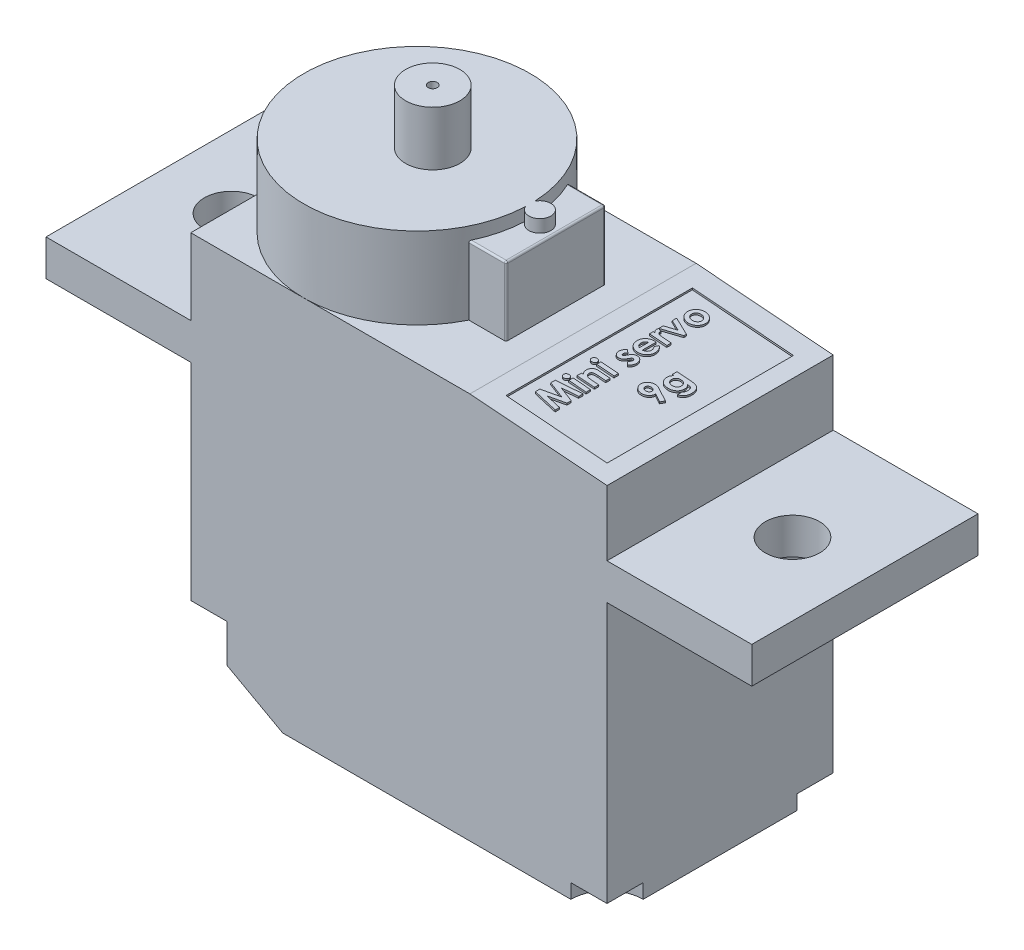
from build123d import *

# Parameters (mm, degrees)
SKETCH1_W                = 23
SKETCH1_H                = 12.5
BOSS_EXTRUDE1_DEPTH      = 15.2
SKETCH2_W                = 39
SKETCH2_H                = 12.5
BOSS_EXTRUDE2_DEPTH      = 2
SKETCH3_W                = 23
SKETCH3_H                = 12.5
BOSS_EXTRUDE3_DEPTH      = 4.2
CUT_EXTRUDE1_DEPTH       = 13.5
SKETCH5_R                = 6.250000507
BOSS_EXTRUDE4_DEPTH      = 4.5
SKETCH6_W                = 4.84744246
SKETCH6_H                = 5.5
BOSS_EXTRUDE5_DEPTH      = 3.8
SKETCH7_R                = 0.605889216
BOSS_EXTRUDE7_DEPTH      = 0.7
SKETCH8_R                = 1.5
BOSS_EXTRUDE8_DEPTH      = 3
CUT_EXTRUDE2_DEPTH       = 13.500001013
SKETCH13_R               = 0.25
CUT_EXTRUDE3_DEPTH       = 7.5
CUT_EXTRUDE12_DEPTH      = 0.8
CUT_EXTRUDE13_DEPTH      = 3.8
SKETCH17_W               = 5.6
SKETCH17_H               = 10.3
CUT_EXTRUDE14_DEPTH      = 0.1
SKETCH19_W               = 0.966746795
SKETCH19_H               = 0.237446581
BOSS_EXTRUDE9_DEPTH      = 0.1
FILLET3_R                = 0.1
F_3_0_3_DIAMETER_HOLE1_D = 3


with BuildPart() as part:
    # Sketch1 → Boss-Extrude1 (new body)
    with BuildSketch(Plane(origin=(0, 0, 0), x_dir=(1, 0, 0), z_dir=(0, 1, 0))):
        Rectangle(SKETCH1_W, SKETCH1_H)
    extrude(amount=BOSS_EXTRUDE1_DEPTH)

    # Sketch2 → Boss-Extrude2 (add)
    with BuildSketch(Plane(origin=(0, 15.2, 0), x_dir=(1, 0, 0), z_dir=(0, 1, 0))):
        Rectangle(SKETCH2_W, SKETCH2_H)
    extrude(amount=BOSS_EXTRUDE2_DEPTH)

    # Sketch3 → Boss-Extrude3 (add)
    with BuildSketch(Plane(origin=(0, 17.2, 0), x_dir=(1, 0, 0), z_dir=(0, 1, 0))):
        Rectangle(SKETCH3_W, SKETCH3_H)
    extrude(amount=BOSS_EXTRUDE3_DEPTH)

    # Sketch4 → Cut-Extrude1 (cut, through all)
    with BuildSketch(Plane.XY.offset(6.25)):
        Polygon((11.5, 20.8), (3.92372123, 21.4), (11.5, 21.4), align=None)
    extrude(amount=-CUT_EXTRUDE1_DEPTH, mode=Mode.SUBTRACT)

    # Sketch5 → Boss-Extrude4 (add)
    with BuildSketch(Plane(origin=(0, 21.4, 0), x_dir=(1, 0, 0), z_dir=(0, 1, 0))):
        with Locations((-5.249999493, 5.07e-07)):
            Circle(SKETCH5_R)
    extrude(amount=BOSS_EXTRUDE4_DEPTH)

    # Sketch6 → Boss-Extrude5 (add)
    with BuildSketch(Plane(origin=(0, 21.4, 0), x_dir=(1, 0, 0), z_dir=(0, 1, 0))):
        Rectangle(SKETCH6_W, SKETCH6_H)
    extrude(amount=BOSS_EXTRUDE5_DEPTH)

    # Sketch7 → Boss-Extrude7 (add)
    with BuildSketch(Plane(origin=(0, 25.2, 0), x_dir=(1, 0, 0), z_dir=(0, 1, 0))):
        with Locations((1.542332806, 0)):
            Circle(SKETCH7_R)
    extrude(amount=BOSS_EXTRUDE7_DEPTH)

    # Sketch8 → Boss-Extrude8 (add)
    with BuildSketch(Plane(origin=(0, 25.9, 0), x_dir=(1, 0, 0), z_dir=(0, 1, 0))):
        with Locations((-4.378885872, 0)):
            Circle(SKETCH8_R)
    extrude(amount=BOSS_EXTRUDE8_DEPTH)

    # Sketch9 → Cut-Extrude2 (cut, through all)
    with BuildSketch(Plane.XY.offset(6.25)):
        Polygon((-11.5, 0), (-6.42062996, 0), (-11.5, 2.8), align=None)
    extrude(amount=-CUT_EXTRUDE2_DEPTH, mode=Mode.SUBTRACT)

    # Sketch13 → Cut-Extrude3 (cut)
    with BuildSketch(Plane(origin=(0, 28.9, 0), x_dir=(1, 0, 0), z_dir=(0, 1, 0))):
        with Locations((-4.378885872, 0)):
            Circle(SKETCH13_R)
    extrude(amount=-CUT_EXTRUDE3_DEPTH, mode=Mode.SUBTRACT)

    # Sketch15 → Cut-Extrude12 (cut)
    with BuildSketch(Plane.XZ):
        with BuildLine():
            Line((9.5, 6.25), (11.5, 6.25))
            Line((11.5, 6.25), (11.5, 4.25))
            ThreePointArc((11.5, 4.25), (10.085786438, 4.835786438), (9.5, 6.25))
        make_face()
        with BuildLine():
            Line((11.5, -6.25), (11.5, -4.25))
            ThreePointArc((11.5, -4.25), (10.085786438, -4.835786438), (9.5, -6.25))
            Line((9.5, -6.25), (11.5, -6.25))
        make_face()
    extrude(amount=-CUT_EXTRUDE12_DEPTH, mode=Mode.SUBTRACT)

    # Sketch16 → Cut-Extrude13 (cut)
    with BuildSketch(Plane.XZ):
        with BuildLine():
            Line((-11.5, 4.25), (-11.5, 6.25))
            Line((-11.5, 6.25), (-9.5, 6.25))
            ThreePointArc((-9.5, 6.25), (-10.085786438, 4.835786438), (-11.5, 4.25))
        make_face()
        with BuildLine():
            Line((-11.5, -6.25), (-9.5, -6.25))
            ThreePointArc((-9.5, -6.25), (-10.085786438, -4.835786438), (-11.5, -4.25))
            Line((-11.5, -4.25), (-11.5, -6.25))
        make_face()
    extrude(amount=-CUT_EXTRUDE13_DEPTH, mode=Mode.SUBTRACT)

    # Sketch17 → Cut-Extrude14 (cut)
    with BuildSketch(Plane(origin=(1.708655801, 21.575421113, 0), x_dir=(0.996878786, -0.078947368, 0), z_dir=(0.078947368, 0.996878786, 0))):
        with Locations((6.02200077, -0.1)):
            Rectangle(SKETCH17_W, SKETCH17_H)
    extrude(amount=-CUT_EXTRUDE14_DEPTH, mode=Mode.SUBTRACT)

    # Sketch19 → Boss-Extrude9 (add)
    with BuildSketch(Plane(origin=(1.700761064, 21.475733235, 0), x_dir=(0.996878786, -0.078947368, 0), z_dir=(0.078947368, 0.996878786, 0))):
        Polygon((3.804977761, -4.209998915), (3.804977761, -3.963542084), (4.727733337, -3.661698718), (3.804977761, -3.357735293), (3.804977761, -3.113663528), (5.127894428, -2.889997329), (5.127894428, -3.130358991), (4.292326269, -3.271607906), (5.127894428, -3.54668553), (5.127894428, -3.77830195), (4.292326269, -4.05178953), (5.127894428, -4.192773437), (5.127894428, -4.433400107), align=None)
        with BuildLine():
            add(Edge.make_bspline(
                [(3.754096351, -2.602199352), (3.75459237, -2.591961906), (3.755566352, -2.571859693), (3.765250821, -2.543162418), (3.779962144, -2.516577279), (3.800736934, -2.493321996), (3.825461159, -2.473783527), (3.853306295, -2.459094906), (3.884008461, -2.450748481), (3.905189995, -2.449608003), (3.916015839, -2.449025107)],
                knots=[0, 0, 0, 0, 3.0615e-05, 6.0115e-05, 8.9897e-05, 0.000121258, 0.000152962, 0.000184016, 0.000215069, 0.000247531, 0.000247531, 0.000247531, 0.000247531], degree=3))
            add(Edge.make_bspline(
                [(3.916015839, -2.449025107), (3.926755073, -2.449605165), (3.947766142, -2.450740036), (3.978075272, -2.459095732), (4.005632722, -2.473557801), (4.02994352, -2.493040352), (4.050299111, -2.516159468), (4.065658572, -2.542001345), (4.074734342, -2.570515674), (4.075802775, -2.590299071), (4.076345283, -2.600344301)],
                knots=[0, 0, 0, 0, 3.2198e-05, 6.2995e-05, 9.3457e-05, 0.000124953, 0.00015594, 0.000185393, 0.000214561, 0.000244648, 0.000244648, 0.000244648, 0.000244648], degree=3))
            add(Edge.make_bspline(
                [(4.076345283, -2.600344301), (4.075838926, -2.610664087), (4.074844674, -2.630927394), (4.065284296, -2.66004514), (4.049948219, -2.686657776), (4.028907377, -2.710017641), (4.004029509, -2.729557175), (3.975889403, -2.743906483), (3.945069935, -2.752707621), (3.923583116, -2.753769392), (3.912570743, -2.754313568)],
                knots=[0, 0, 0, 0, 3.0879e-05, 6.0632e-05, 9.0905e-05, 0.000122442, 0.000154354, 0.000185288, 0.000216666, 0.000249656, 0.000249656, 0.000249656, 0.000249656], degree=3))
            add(Edge.make_bspline(
                [(3.912570743, -2.754313568), (3.902009274, -2.753725713), (3.881262794, -2.752570957), (3.851287745, -2.744252881), (3.824083661, -2.729750005), (3.799821827, -2.710462573), (3.779512344, -2.687309295), (3.764886508, -2.660902407), (3.755672611, -2.632306853), (3.754627196, -2.61233881), (3.754096351, -2.602199352)],
                knots=[0, 0, 0, 0, 3.167e-05, 6.2212e-05, 9.2439e-05, 0.000123562, 0.00015475, 0.000184171, 0.000213591, 0.000243942, 0.000243942, 0.000243942, 0.000243942], degree=3))
        make_face()
        with Locations((4.64452103, -2.601669338)):
            Rectangle(SKETCH19_W, SKETCH19_H)
        with BuildLine():
            Line((4.161147633, -2.262459936), (4.161147633, -2.025013355))
            Line((4.161147633, -2.025013355), (4.263440468, -2.025013355))
            add(Edge.make_bspline(
                [(4.263440468, -2.025013355), (4.252895408, -2.011471852), (4.232741746, -1.985591407), (4.207153626, -1.946137744), (4.185757128, -1.909151347), (4.169870375, -1.873291895), (4.158236054, -1.838291066), (4.150419303, -1.80328736), (4.145017255, -1.768035338), (4.144463712, -1.744302244), (4.144187163, -1.732445246)],
                knots=[0, 0, 0, 0, 5.1465e-05, 9.8359e-05, 0.000140959, 0.000179518, 0.000215804, 0.000251419, 0.000287023, 0.000322569, 0.000322569, 0.000322569, 0.000322569], degree=3))
            add(Edge.make_bspline(
                [(4.144187163, -1.732445246), (4.144472419, -1.720413512), (4.145032681, -1.696782417), (4.15005373, -1.662119501), (4.157614767, -1.628794919), (4.16856507, -1.59683021), (4.182668476, -1.566184116), (4.199989685, -1.537046684), (4.220179715, -1.50914136), (4.235873487, -1.492194884), (4.243829925, -1.483603349)],
                knots=[0, 0, 0, 0, 3.6076e-05, 7.0856e-05, 0.000104861, 0.000138467, 0.000172024, 0.000205884, 0.000240019, 0.000275121, 0.000275121, 0.000275121, 0.000275121], degree=3))
            add(Edge.make_bspline(
                [(4.243829925, -1.483603349), (4.251177599, -1.476696585), (4.265926724, -1.46283251), (4.291171464, -1.445399264), (4.318743463, -1.430347031), (4.348923799, -1.41826973), (4.381735287, -1.409035118), (4.416900166, -1.402131615), (4.454686424, -1.39820407), (4.480649169, -1.397723188), (4.493996859, -1.397475962)],
                knots=[0, 0, 0, 0, 3.0217e-05, 6.0654e-05, 9.1724e-05, 0.000124301, 0.000157936, 0.000193849, 0.00023169, 0.000271728, 0.000271728, 0.000271728, 0.000271728], degree=3))
            Line((4.493996859, -1.397475962), (5.127894428, -1.397475962))
            Line((5.127894428, -1.397475962), (5.127894428, -1.634922543))
            Line((5.127894428, -1.634922543), (4.708122793, -1.634922543))
            add(Edge.make_bspline(
                [(4.708122793, -1.634922543), (4.694430569, -1.634972733), (4.668191963, -1.635068913), (4.630640648, -1.635808044), (4.596726682, -1.637249596), (4.566389395, -1.638567758), (4.53973313, -1.64113921), (4.516512884, -1.64350685), (4.496996733, -1.64701419), (4.476038704, -1.651710565), (4.453705894, -1.659720001), (4.43031827, -1.672584349), (4.410099694, -1.688292983), (4.393521681, -1.707140929), (4.380279706, -1.728484577), (4.371449805, -1.75249671), (4.365584458, -1.778628512), (4.36498473, -1.796895655), (4.364673274, -1.806382295)],
                knots=[0, 0, 0, 0, 4.1077e-05, 7.8716e-05, 0.000112663, 0.000142916, 0.000169788, 0.000192995, 0.000212906, 0.000229234, 0.000257399, 0.000283731, 0.00030902, 0.0003338, 0.000358662, 0.00038391, 0.000410211, 0.000438627, 0.000438627, 0.000438627, 0.000438627], degree=3))
            add(Edge.make_bspline(
                [(4.364673274, -1.806382295), (4.365300058, -1.818714845), (4.366526168, -1.84283971), (4.375733221, -1.877747918), (4.391472627, -1.909699074), (4.412865203, -1.938806589), (4.439740262, -1.964369847), (4.471892035, -1.985267733), (4.508285748, -2.002626573), (4.534841665, -2.010043608), (4.548588372, -2.013883046)],
                knots=[0, 0, 0, 0, 3.6973e-05, 7.2326e-05, 0.000107409, 0.00014324, 0.000180167, 0.000218019, 0.000257852, 0.000300599, 0.000300599, 0.000300599, 0.000300599], degree=3))
            add(Edge.make_bspline(
                [(4.548588372, -2.013883046), (4.552904782, -2.014838435), (4.562531244, -2.016969143), (4.578794152, -2.018720308), (4.598175752, -2.021173637), (4.620852782, -2.02205164), (4.646799373, -2.02367027), (4.675967638, -2.024244313), (4.708473615, -2.024836211), (4.731177961, -2.024952351), (4.743103763, -2.025013355)],
                knots=[0, 0, 0, 0, 1.3253e-05, 2.9557e-05, 4.9018e-05, 7.1847e-05, 9.7587e-05, 0.000127014, 0.000159349, 0.000195126, 0.000195126, 0.000195126, 0.000195126], degree=3))
            Line((4.743103763, -2.025013355), (5.127894428, -2.025013355))
            Line((5.127894428, -2.025013355), (5.127894428, -2.262459936))
            Line((5.127894428, -2.262459936), (4.161147633, -2.262459936))
        make_face()
        with BuildLine():
            add(Edge.make_bspline(
                [(3.754096351, -1.058796575), (3.75459237, -1.048559128), (3.755566352, -1.028456916), (3.765250821, -0.99975964), (3.779962144, -0.973174502), (3.800736934, -0.949919219), (3.825461159, -0.930380749), (3.853306295, -0.915692128), (3.884008461, -0.907345704), (3.905189995, -0.906205225), (3.916015839, -0.905622329)],
                knots=[0, 0, 0, 0, 3.0615e-05, 6.0115e-05, 8.9897e-05, 0.000121258, 0.000152962, 0.000184016, 0.000215069, 0.000247531, 0.000247531, 0.000247531, 0.000247531], degree=3))
            add(Edge.make_bspline(
                [(3.916015839, -0.905622329), (3.926755073, -0.906202387), (3.947766142, -0.907337258), (3.978075272, -0.915692954), (4.005632722, -0.930155023), (4.02994352, -0.949637574), (4.050299111, -0.97275669), (4.065658572, -0.998598568), (4.074734342, -1.027112897), (4.075802775, -1.046896293), (4.076345283, -1.056941523)],
                knots=[0, 0, 0, 0, 3.2198e-05, 6.2995e-05, 9.3457e-05, 0.000124953, 0.00015594, 0.000185393, 0.000214561, 0.000244648, 0.000244648, 0.000244648, 0.000244648], degree=3))
            add(Edge.make_bspline(
                [(4.076345283, -1.056941523), (4.075838926, -1.067261309), (4.074844674, -1.087524616), (4.065284296, -1.116642362), (4.049948219, -1.143254998), (4.028907377, -1.166614864), (4.004029509, -1.186154397), (3.975889403, -1.200503706), (3.945069935, -1.209304843), (3.923583116, -1.210366614), (3.912570743, -1.210910791)],
                knots=[0, 0, 0, 0, 3.0879e-05, 6.0632e-05, 9.0905e-05, 0.000122442, 0.000154354, 0.000185288, 0.000216666, 0.000249656, 0.000249656, 0.000249656, 0.000249656], degree=3))
            add(Edge.make_bspline(
                [(3.912570743, -1.210910791), (3.902009274, -1.210322936), (3.881262794, -1.209168179), (3.851287745, -1.200850104), (3.824083661, -1.186347227), (3.799821827, -1.167059795), (3.779512344, -1.143906517), (3.764886508, -1.117499629), (3.755672611, -1.088904075), (3.754627196, -1.068936033), (3.754096351, -1.058796575)],
                knots=[0, 0, 0, 0, 3.167e-05, 6.2212e-05, 9.2439e-05, 0.000123562, 0.00015475, 0.000184171, 0.000213591, 0.000243942, 0.000243942, 0.000243942, 0.000243942], degree=3))
        make_face()
        with Locations((4.64452103, -1.05826656)):
            Rectangle(SKETCH19_W, SKETCH19_H)
        with BuildLine():
            Line((4.310346768, 0.383373397), (4.466436095, 0.238149372))
            add(Edge.make_bspline(
                [(4.466436095, 0.238149372), (4.458411661, 0.230897641), (4.443063959, 0.217027826), (4.42214161, 0.19579448), (4.404719475, 0.17487734), (4.390084155, 0.154666195), (4.378860614, 0.134748261), (4.370785527, 0.115289102), (4.365659342, 0.09627938), (4.364995777, 0.083678933), (4.364673274, 0.077554921)],
                knots=[0, 0, 0, 0, 3.2445e-05, 6.2054e-05, 8.9335e-05, 0.000114042, 0.000136822, 0.000157737, 0.000177148, 0.000195502, 0.000195502, 0.000195502, 0.000195502], degree=3))
            add(Edge.make_bspline(
                [(4.364673274, 0.077554921), (4.364862134, 0.071358036), (4.365223742, 0.05949293), (4.36832543, 0.042748605), (4.373695023, 0.028037596), (4.38101428, 0.015589477), (4.390030852, 0.005588438), (4.400345598, -0.001413756), (4.411637705, -0.006115794), (4.419658925, -0.006513556), (4.423769912, -0.006717415)],
                knots=[0, 0, 0, 0, 1.8581e-05, 3.5576e-05, 5.0837e-05, 6.5335e-05, 7.8651e-05, 9.0853e-05, 0.000102517, 0.000114779, 0.000114779, 0.000114779, 0.000114779], degree=3))
            add(Edge.make_bspline(
                [(4.423769912, -0.006717415), (4.429999834, -0.006026723), (4.442926199, -0.004593619), (4.457918854, 0.005249822), (4.468978629, 0.018273405), (4.479270384, 0.033285831), (4.490777669, 0.053616541), (4.498657043, 0.069039934), (4.503007108, 0.077554921)],
                knots=[0, 0, 0, 0, 1.8607e-05, 3.8608e-05, 5.1746e-05, 6.9831e-05, 9.3104e-05, 0.000121788, 0.000121788, 0.000121788, 0.000121788], degree=3))
            Line((4.503007108, 0.077554921), (4.546468313, 0.163417301))
            add(Edge.make_bspline(
                [(4.546468313, 0.163417301), (4.552012371, 0.174342414), (4.562768887, 0.195539185), (4.580166995, 0.22531091), (4.596910375, 0.2529569), (4.614548494, 0.277363506), (4.6315577, 0.299650815), (4.649266113, 0.318725676), (4.66663527, 0.335555581), (4.689956301, 0.354300833), (4.721007202, 0.37305852), (4.761391978, 0.388694119), (4.804634, 0.398665374), (4.834563654, 0.399768531), (4.849901723, 0.400333868)],
                knots=[0, 0, 0, 0, 3.6744e-05, 7.1291e-05, 0.000103427, 0.000133648, 0.000161586, 0.00018747, 0.00021165, 0.000234082, 0.000277122, 0.000319837, 0.000363557, 0.000409513, 0.000409513, 0.000409513, 0.000409513], degree=3))
            add(Edge.make_bspline(
                [(4.849901723, 0.400333868), (4.860249279, 0.399992958), (4.880502193, 0.399325709), (4.910315033, 0.395114986), (4.938653049, 0.387529508), (4.96592948, 0.377647433), (4.991566802, 0.364076491), (5.015941096, 0.347877032), (5.039267105, 0.32895112), (5.060771519, 0.306951087), (5.08069072, 0.282714428), (5.097975095, 0.256157985), (5.112234484, 0.227511698), (5.124309895, 0.197156425), (5.133541298, 0.164651356), (5.140075024, 0.130151664), (5.144149087, 0.093641178), (5.144615633, 0.068643987), (5.144854898, 0.055824319)],
                knots=[0, 0, 0, 0, 3.1047e-05, 6.0766e-05, 9.0077e-05, 0.000118923, 0.000147607, 0.00017686, 0.000206619, 0.000237539, 0.000268994, 0.000300601, 0.000332364, 0.000364843, 0.000398478, 0.00043356, 0.000470083, 0.000508532, 0.000508532, 0.000508532, 0.000508532], degree=3))
            add(Edge.make_bspline(
                [(5.144854898, 0.055824319), (5.144314006, 0.038838887), (5.143252284, 0.005497979), (5.135856475, -0.043194003), (5.123054206, -0.08917216), (5.105119865, -0.132474321), (5.082266598, -0.173365705), (5.053910696, -0.211262336), (5.02079095, -0.246821188), (4.995389648, -0.267509698), (4.982405396, -0.278084936)],
                knots=[0, 0, 0, 0, 5.095e-05, 0.000100011, 0.000147334, 0.000193792, 0.000240304, 0.000287476, 0.000335471, 0.000385659, 0.000385659, 0.000385659, 0.000385659], degree=3))
            Line((4.982405396, -0.278084936), (4.822605966, -0.134185948))
            add(Edge.make_bspline(
                [(4.822605966, -0.134185948), (4.829976995, -0.127155304), (4.844652167, -0.113157812), (4.864364835, -0.089970439), (4.881622161, -0.064861726), (4.896561886, -0.038529818), (4.908343449, -0.011961111), (4.917871849, 0.013266089), (4.922989826, 0.037245738), (4.923924579, 0.052713802), (4.924368787, 0.060064436)],
                knots=[0, 0, 0, 0, 3.0545e-05, 6.0813e-05, 9.1099e-05, 0.000121833, 0.000151485, 0.000178225, 0.000202601, 0.000224675, 0.000224675, 0.000224675, 0.000224675], degree=3))
            add(Edge.make_bspline(
                [(4.924368787, 0.060064436), (4.924155729, 0.067418104), (4.923746173, 0.081553884), (4.919488871, 0.101646665), (4.912325846, 0.11944803), (4.902413191, 0.134570882), (4.891022432, 0.147005385), (4.878231414, 0.156115914), (4.86438933, 0.161763388), (4.854721202, 0.162513408), (4.849901723, 0.162887286)],
                knots=[0, 0, 0, 0, 2.2035e-05, 4.2358e-05, 6.1256e-05, 7.9265e-05, 9.6326e-05, 0.000111545, 0.000126063, 0.000140493, 0.000140493, 0.000140493, 0.000140493], degree=3))
            add(Edge.make_bspline(
                [(4.849901723, 0.162887286), (4.845356364, 0.162568182), (4.836023866, 0.161913), (4.822248431, 0.1567259), (4.80860854, 0.148582051), (4.795065737, 0.137286977), (4.781729904, 0.122690382), (4.768707857, 0.104844504), (4.755304854, 0.084161048), (4.747305057, 0.068883071), (4.743103763, 0.060859458)],
                knots=[0, 0, 0, 0, 1.3609e-05, 2.7941e-05, 4.3621e-05, 6.113e-05, 8.0633e-05, 0.000102787, 0.00012734, 0.000154497, 0.000154497, 0.000154497, 0.000154497], degree=3))
            Line((4.743103763, 0.060859458), (4.703352661, -0.017847723))
            add(Edge.make_bspline(
                [(4.703352661, -0.017847723), (4.693778669, -0.035701654), (4.675400194, -0.069974507), (4.643885016, -0.116298592), (4.610336481, -0.155505243), (4.574934824, -0.187626409), (4.537779391, -0.213220617), (4.498397119, -0.231074295), (4.457161363, -0.242305889), (4.428963906, -0.243541544), (4.414759662, -0.244163996)],
                knots=[0, 0, 0, 0, 6.0746e-05, 0.00011661, 0.000167717, 0.000215189, 0.000259657, 0.000302469, 0.000344378, 0.000386919, 0.000386919, 0.000386919, 0.000386919], degree=3))
            add(Edge.make_bspline(
                [(4.414759662, -0.244163996), (4.4055536, -0.243948499), (4.387480604, -0.243525443), (4.360942704, -0.239008963), (4.335419189, -0.232212753), (4.310862392, -0.222494372), (4.287146379, -0.210434323), (4.264810914, -0.194978347), (4.243198378, -0.177225831), (4.223001804, -0.156666391), (4.204607635, -0.13400435), (4.188229119, -0.109823584), (4.174713643, -0.083892204), (4.163557278, -0.056471932), (4.154767991, -0.027568018), (4.148768284, 0.002889111), (4.144959167, 0.034792376), (4.144448144, 0.056608233), (4.144187163, 0.067749649)],
                knots=[0, 0, 0, 0, 2.7593e-05, 5.4169e-05, 8.0526e-05, 0.000106707, 0.000133257, 0.000160158, 0.000188016, 0.000217061, 0.000246447, 0.00027548, 0.000304522, 0.000334, 0.000364181, 0.000395, 0.000427017, 0.000460434, 0.000460434, 0.000460434, 0.000460434], degree=3))
            add(Edge.make_bspline(
                [(4.144187163, 0.067749649), (4.14465733, 0.08316049), (4.145591007, 0.113763994), (4.154281028, 0.158729483), (4.1674315, 0.202421445), (4.186430722, 0.244247137), (4.210096034, 0.283950892), (4.238892919, 0.320568862), (4.272048301, 0.354367016), (4.297453842, 0.37360859), (4.310346768, 0.383373397)],
                knots=[0, 0, 0, 0, 4.6187e-05, 9.1721e-05, 0.000136904, 0.000182808, 0.000229165, 0.000275233, 0.000322267, 0.000370732, 0.000370732, 0.000370732, 0.000370732], degree=3))
        make_face()
        with BuildLine():
            Line((4.703882676, 1.569811281), (4.703882676, 0.80738515))
            add(Edge.make_bspline(
                [(4.703882676, 0.80738515), (4.712740184, 0.808943586), (4.730145885, 0.812006038), (4.755373315, 0.818563015), (4.779130002, 0.827218054), (4.801611091, 0.837172271), (4.822737029, 0.848820193), (4.84222609, 0.862574105), (4.860479341, 0.877834698), (4.877229835, 0.894891072), (4.892283044, 0.913306255), (4.905369645, 0.933130455), (4.916540495, 0.954040769), (4.925556522, 0.976275954), (4.932788557, 0.999657643), (4.937750559, 1.024340866), (4.940688078, 1.050237284), (4.941112374, 1.067879601), (4.941329257, 1.07689762)],
                knots=[0, 0, 0, 0, 2.6975e-05, 5.3008e-05, 7.8072e-05, 0.000102746, 0.000126709, 0.000150309, 0.000174196, 0.000197995, 0.000221918, 0.000245438, 0.000269148, 0.000292918, 0.000317311, 0.000342466, 0.000368337, 0.000395388, 0.000395388, 0.000395388, 0.000395388], degree=3))
            add(Edge.make_bspline(
                [(4.941329257, 1.07689762), (4.941041875, 1.087782888), (4.940475936, 1.109219187), (4.935456898, 1.140623525), (4.927875861, 1.170996094), (4.916602223, 1.200049463), (4.902568525, 1.22812017), (4.885084264, 1.254746084), (4.864660388, 1.28038808), (4.848917672, 1.296032719), (4.840891473, 1.304008914)],
                knots=[0, 0, 0, 0, 3.2635e-05, 6.4267e-05, 9.5184e-05, 0.000126387, 0.000157557, 0.000189164, 0.000221777, 0.000255699, 0.000255699, 0.000255699, 0.000255699], degree=3))
            Line((4.840891473, 1.304008914), (4.935499095, 1.502764423))
            add(Edge.make_bspline(
                [(4.935499095, 1.502764423), (4.944146395, 1.496506806), (4.961280701, 1.484107568), (4.985391064, 1.463864728), (5.007894909, 1.44274586), (5.028607158, 1.420708481), (5.047570511, 1.397861302), (5.064561851, 1.373878538), (5.079870497, 1.348958325), (5.093835037, 1.323229223), (5.105669271, 1.296186971), (5.116408458, 1.268236713), (5.124990924, 1.238834091), (5.132595099, 1.208391768), (5.137996385, 1.176570222), (5.141989872, 1.143585618), (5.144416043, 1.109353309), (5.144706875, 1.08608846), (5.144854898, 1.074247546)],
                knots=[0, 0, 0, 0, 3.2013e-05, 6.3433e-05, 9.4366e-05, 0.000124551, 0.000154104, 0.000183371, 0.000212642, 0.000241808, 0.00027111, 0.000301135, 0.000331569, 0.000362935, 0.000395219, 0.00042832, 0.000462589, 0.000498109, 0.000498109, 0.000498109, 0.000498109], degree=3))
            add(Edge.make_bspline(
                [(5.144854898, 1.074247546), (5.1444835, 1.056030143), (5.143756138, 1.020352408), (5.137005181, 0.968167271), (5.125811366, 0.918605866), (5.110595094, 0.871528247), (5.090504848, 0.827137916), (5.06593281, 0.785412903), (5.037350076, 0.745936317), (5.004156771, 0.709914387), (4.968027831, 0.677097346), (4.929227817, 0.648272897), (4.888027809, 0.624153009), (4.844700478, 0.604345272), (4.799134923, 0.588950011), (4.75131126, 0.57785092), (4.701252331, 0.571047045), (4.667156612, 0.570312193), (4.649821177, 0.569938568)],
                knots=[0, 0, 0, 0, 5.4633e-05, 0.000106995, 0.000157527, 0.000206888, 0.000255161, 0.000303384, 0.000351937, 0.000401085, 0.000450054, 0.00049818, 0.000545812, 0.00059301, 0.000640862, 0.000689845, 0.000740105, 0.00079209, 0.00079209, 0.00079209, 0.00079209], degree=3))
            add(Edge.make_bspline(
                [(4.649821177, 0.569938568), (4.632045227, 0.57031587), (4.597071844, 0.571058193), (4.545857031, 0.577792339), (4.496991172, 0.588980696), (4.450406974, 0.604420992), (4.405958742, 0.623928243), (4.364035343, 0.648355015), (4.324490825, 0.677083042), (4.28751018, 0.70978186), (4.254131107, 0.74595639), (4.224383683, 0.784395246), (4.199596154, 0.825530327), (4.179567847, 0.868896362), (4.163295352, 0.914215964), (4.152467366, 0.962012964), (4.145197022, 1.011923702), (4.144527468, 1.046041583), (4.144187163, 1.063382245)],
                knots=[0, 0, 0, 0, 5.3309e-05, 0.000104882, 0.00015464, 0.000203497, 0.000251903, 0.000299993, 0.000348761, 0.000398322, 0.000447828, 0.000496221, 0.000543896, 0.000591557, 0.000639332, 0.000688057, 0.000738352, 0.000790337, 0.000790337, 0.000790337, 0.000790337], degree=3))
            add(Edge.make_bspline(
                [(4.144187163, 1.063382245), (4.144563588, 1.081687281), (4.145302659, 1.117627333), (4.152009186, 1.170170851), (4.163233887, 1.220079591), (4.178441937, 1.267424143), (4.19854815, 1.312065881), (4.223017494, 1.354042689), (4.251792289, 1.393548424), (4.28490249, 1.429987521), (4.321525451, 1.462992516), (4.361376792, 1.491925134), (4.404138733, 1.516308875), (4.449707993, 1.536287588), (4.498057821, 1.551651519), (4.549143965, 1.562765234), (4.603175099, 1.569515997), (4.640172749, 1.570237346), (4.659096435, 1.570606303)],
                knots=[0, 0, 0, 0, 5.4897e-05, 0.000107786, 0.000158576, 0.000208189, 0.000256703, 0.000305155, 0.000353709, 0.000403052, 0.000452592, 0.00050136, 0.000550501, 0.000599984, 0.000650353, 0.000702438, 0.000756641, 0.000813392, 0.000813392, 0.000813392, 0.000813392], degree=3))
            Line((4.659096435, 1.570606303), (4.703882676, 1.569811281))
        make_face()
        with BuildLine():
            add(Edge.make_bspline(
                [(4.517317505, 1.333159722), (4.505212802, 1.328698144), (4.481216317, 1.319853467), (4.448235811, 1.299469926), (4.41926924, 1.273052621), (4.39389435, 1.241853747), (4.373111704, 1.206462071), (4.358688893, 1.167493173), (4.349189126, 1.126024733), (4.348211629, 1.097357114), (4.347712804, 1.082727781)],
                knots=[0, 0, 0, 0, 3.8631e-05, 7.6583e-05, 0.000115427, 0.000155739, 0.000196828, 0.000237926, 0.000279979, 0.000323802, 0.000323802, 0.000323802, 0.000323802], degree=3))
            add(Edge.make_bspline(
                [(4.347712804, 1.082727781), (4.348379385, 1.066772716), (4.349681364, 1.035608994), (4.359768606, 0.990414475), (4.376339034, 0.948195595), (4.39259033, 0.923045445), (4.400714273, 0.910473007)],
                knots=[0, 0, 0, 0, 4.7826e-05, 9.3414e-05, 0.000138245, 0.000183057, 0.000183057, 0.000183057, 0.000183057], degree=3))
            add(Edge.make_bspline(
                [(4.400714273, 0.910473007), (4.40699967, 0.902630092), (4.42044218, 0.885856536), (4.447433826, 0.86444999), (4.479653579, 0.842821254), (4.504245551, 0.830757926), (4.517317505, 0.82434562)],
                knots=[0, 0, 0, 0, 3.0066e-05, 6.4303e-05, 0.000102743, 0.000146363, 0.000146363, 0.000146363, 0.000146363], degree=3))
            Line((4.517317505, 0.82434562), (4.517317505, 1.333159722))
        make_face(mode=Mode.SUBTRACT)
        with BuildLine():
            Line((4.161147633, 1.740211004), (4.161147633, 1.943736645))
            Line((4.161147633, 1.943736645), (4.280135931, 1.943736645))
            add(Edge.make_bspline(
                [(4.280135931, 1.943736645), (4.269556408, 1.949489116), (4.248878291, 1.960732558), (4.221154724, 1.981510672), (4.197505641, 2.005071327), (4.178081803, 2.03116298), (4.162790597, 2.059356218), (4.152393538, 2.089298761), (4.145264799, 2.1203407), (4.144548962, 2.141568482), (4.144187163, 2.152297426)],
                knots=[0, 0, 0, 0, 3.6092e-05, 7.0543e-05, 0.000103523, 0.000135907, 0.000167802, 0.000199319, 0.000230765, 0.000262901, 0.000262901, 0.000262901, 0.000262901], degree=3))
            add(Edge.make_bspline(
                [(4.144187163, 2.152297426), (4.144518711, 2.160092883), (4.145194538, 2.175983156), (4.150045772, 2.200036549), (4.157313776, 2.224697803), (4.164407907, 2.240790707), (4.168037824, 2.249025107)],
                knots=[0, 0, 0, 0, 2.3375e-05, 4.7647e-05, 7.3386e-05, 0.000100355, 0.000100355, 0.000100355, 0.000100355], degree=3))
            Line((4.168037824, 2.249025107), (4.369178399, 2.175353065))
            add(Edge.make_bspline(
                [(4.369178399, 2.175353065), (4.365996735, 2.168767836), (4.360016431, 2.156390142), (4.352959057, 2.138419878), (4.348652992, 2.122111119), (4.34801049, 2.111771665), (4.347712804, 2.10698117)],
                knots=[0, 0, 0, 0, 2.1933e-05, 4.1226e-05, 5.7873e-05, 7.2245e-05, 7.2245e-05, 7.2245e-05, 7.2245e-05], degree=3))
            add(Edge.make_bspline(
                [(4.347712804, 2.10698117), (4.347908395, 2.102456885), (4.348293156, 2.093556836), (4.35164296, 2.08044029), (4.357300696, 2.067963585), (4.365032019, 2.056034329), (4.374874651, 2.044681076), (4.386765627, 2.033747849), (4.401328625, 2.02397192), (4.417585579, 2.013692371), (4.437468353, 2.004930067), (4.461209231, 1.997419777), (4.489077151, 1.990726984), (4.521221983, 1.986121721), (4.557332049, 1.981670429), (4.597672593, 1.979020938), (4.64211599, 1.977046228), (4.673139088, 1.976925489), (4.689307272, 1.976862563)],
                knots=[0, 0, 0, 0, 1.3557e-05, 2.6669e-05, 4.0311e-05, 5.4498e-05, 6.9157e-05, 8.529e-05, 0.000102789, 0.000121696, 0.000142926, 0.000167732, 0.000196336, 0.000228795, 0.000265084, 0.000305471, 0.00035003, 0.00039853, 0.00039853, 0.00039853, 0.00039853], degree=3))
            Line((4.689307272, 1.976862563), (4.736478579, 1.977657585))
            Line((4.736478579, 1.977657585), (5.127894428, 1.977657585))
            Line((5.127894428, 1.977657585), (5.127894428, 1.740211004))
            Line((5.127894428, 1.740211004), (4.161147633, 1.740211004))
        make_face()
        Polygon((4.161147633, 2.257505342), (4.161147633, 2.499192041), (4.731708447, 2.749358974), (4.161147633, 2.999525908), (4.161147633, 3.241212607), (5.127894428, 2.817730869), (5.127894428, 2.680987079), align=None)
        with BuildLine():
            add(Edge.make_bspline(
                [(4.144187163, 3.862919838), (4.144384274, 3.874146501), (4.144774642, 3.896380379), (4.148106999, 3.929483602), (4.153336085, 3.962072464), (4.16084119, 3.994075583), (4.170048487, 4.025675187), (4.181878379, 4.056535502), (4.195261458, 4.087224595), (4.211252654, 4.116886944), (4.228573983, 4.14576456), (4.24771374, 4.173114777), (4.268422332, 4.198883295), (4.290633096, 4.222984756), (4.314363687, 4.245279241), (4.33935949, 4.266183855), (4.366153691, 4.285112902), (4.394167106, 4.302612828), (4.423204221, 4.318199612), (4.453072078, 4.331732107), (4.483355329, 4.343477505), (4.514423484, 4.352673803), (4.545866699, 4.360287521), (4.578070332, 4.365092311), (4.610703558, 4.368508186), (4.632674932, 4.368891214), (4.643726008, 4.369083868)],
                knots=[0, 0, 0, 0, 3.3673e-05, 6.6687e-05, 9.9711e-05, 0.000132624, 0.000165242, 0.000198368, 0.000231706, 0.000265611, 0.00029938, 0.000332683, 0.000365669, 0.000398488, 0.00043092, 0.00046329, 0.00049616, 0.000529251, 0.000562331, 0.000594944, 0.000627574, 0.000659684, 0.000692081, 0.00072454, 0.00075729, 0.000790433, 0.000790433, 0.000790433, 0.000790433], degree=3))
            add(Edge.make_bspline(
                [(4.643726008, 4.369083868), (4.654863339, 4.368880303), (4.677006878, 4.368475572), (4.709948265, 4.365218831), (4.742298814, 4.359811143), (4.774193544, 4.35289633), (4.805289461, 4.343004433), (4.836110279, 4.331912089), (4.866078183, 4.31778199), (4.895661464, 4.302365348), (4.924144239, 4.285011444), (4.951051048, 4.265751159), (4.976431243, 4.245109509), (5.000422318, 4.223156854), (5.022476084, 4.199418576), (5.042904332, 4.174105043), (5.0619827, 4.147468171), (5.079256613, 4.119307527), (5.094434949, 4.089986205), (5.108119357, 4.059998057), (5.119512629, 4.029167902), (5.128803522, 3.997559499), (5.13599723, 3.965153691), (5.140884001, 3.932022018), (5.144282694, 3.898235834), (5.144662935, 3.875472034), (5.144854898, 3.863979868)],
                knots=[0, 0, 0, 0, 3.3408e-05, 6.6422e-05, 9.9185e-05, 0.000131781, 0.000164221, 0.000197006, 0.00022997, 0.000263518, 0.00029706, 0.00032993, 0.00036271, 0.000395154, 0.000427405, 0.000459812, 0.000492682, 0.000525634, 0.000558823, 0.000591678, 0.000624463, 0.000657334, 0.000690448, 0.000723954, 0.00075776, 0.000792227, 0.000792227, 0.000792227, 0.000792227], degree=3))
            add(Edge.make_bspline(
                [(5.144854898, 3.863979868), (5.144361022, 3.847176311), (5.143387586, 3.814056245), (5.136737867, 3.765272454), (5.12524152, 3.718429658), (5.109377995, 3.673309923), (5.088425821, 3.630329261), (5.063574482, 3.588905662), (5.033444157, 3.549875299), (4.999713438, 3.512849248), (4.962582956, 3.479183704), (4.923200715, 3.449476696), (4.881691863, 3.424506735), (4.838223134, 3.403901001), (4.792720984, 3.388014398), (4.745341284, 3.376537239), (4.695945497, 3.369870386), (4.662384774, 3.368906405), (4.645316053, 3.368416132)],
                knots=[0, 0, 0, 0, 5.0408e-05, 9.9355e-05, 0.000147368, 0.000194893, 0.000242541, 0.000290581, 0.000339555, 0.0003902, 0.000440667, 0.000489693, 0.000537959, 0.000585733, 0.000633757, 0.000682286, 0.000731758, 0.00078296, 0.00078296, 0.00078296, 0.00078296], degree=3))
            add(Edge.make_bspline(
                [(4.645316053, 3.368416132), (4.627090382, 3.368923479), (4.591268191, 3.36992066), (4.538787864, 3.377838711), (4.488540439, 3.390482985), (4.440666473, 3.408633043), (4.395077668, 3.431818146), (4.351870177, 3.460121902), (4.311034214, 3.493684191), (4.286335223, 3.519386184), (4.273775755, 3.532455679)],
                knots=[0, 0, 0, 0, 5.4656e-05, 0.000107425, 0.000158844, 0.000209836, 0.00026068, 0.000311985, 0.000364511, 0.000418853, 0.000418853, 0.000418853, 0.000418853], degree=3))
            add(Edge.make_bspline(
                [(4.273775755, 3.532455679), (4.263365369, 3.544448248), (4.242827832, 3.568107103), (4.216779333, 3.606544956), (4.194281377, 3.64590098), (4.175783873, 3.686646874), (4.161837053, 3.728896227), (4.151685016, 3.772432535), (4.145449338, 3.817246745), (4.144610026, 3.847618106), (4.144187163, 3.862919838)],
                knots=[0, 0, 0, 0, 4.7605e-05, 9.3914e-05, 0.000139012, 0.000183491, 0.000227906, 0.000272261, 0.00031746, 0.000363355, 0.000363355, 0.000363355, 0.000363355], degree=3))
        make_face()
        with BuildLine():
            add(Edge.make_bspline(
                [(4.364673274, 3.868219985), (4.364967766, 3.859023545), (4.365547476, 3.840920252), (4.368930707, 3.814347082), (4.374970655, 3.788977887), (4.384022748, 3.764993219), (4.394672475, 3.741785332), (4.408357737, 3.720008385), (4.424430209, 3.699498317), (4.442567651, 3.680174762), (4.462846251, 3.662912363), (4.484548189, 3.647603438), (4.507545273, 3.634517821), (4.532193721, 3.624286023), (4.557952671, 3.615927215), (4.585233823, 3.610249934), (4.613753217, 3.606304657), (4.633288386, 3.606011429), (4.643195994, 3.605862714)],
                knots=[0, 0, 0, 0, 2.7593e-05, 5.4316e-05, 8.0219e-05, 0.000105623, 0.00013111, 0.000156701, 0.00018257, 0.00020919, 0.000236066, 0.000262313, 0.000288774, 0.000315255, 0.000342242, 0.000369894, 0.000398754, 0.000428454, 0.000428454, 0.000428454, 0.000428454], degree=3))
            add(Edge.make_bspline(
                [(4.643195994, 3.605862714), (4.653453111, 3.606036512), (4.673498677, 3.606376166), (4.702767121, 3.609896291), (4.730545607, 3.615694832), (4.756777657, 3.623954211), (4.781628773, 3.634237305), (4.804862064, 3.647112712), (4.826594713, 3.662232607), (4.846741686, 3.679464783), (4.86493274, 3.698461082), (4.88102089, 3.718860656), (4.894156089, 3.740837459), (4.90557151, 3.763647189), (4.913901521, 3.787927454), (4.920154778, 3.813269986), (4.9234952, 3.839952431), (4.924073587, 3.858141531), (4.924368787, 3.867424963)],
                knots=[0, 0, 0, 0, 3.0759e-05, 6.0113e-05, 8.8283e-05, 0.000115775, 0.0001425, 0.000168832, 0.000195297, 0.000221799, 0.000248227, 0.000274096, 0.000299548, 0.000324911, 0.000350474, 0.000376377, 0.000403101, 0.000430959, 0.000430959, 0.000430959, 0.000430959], degree=3))
            add(Edge.make_bspline(
                [(4.924368787, 3.867424963), (4.924107565, 3.876713394), (4.923595417, 3.894924109), (4.919760243, 3.921632876), (4.913724434, 3.947123137), (4.905206178, 3.971506972), (4.894033326, 3.994587207), (4.880348511, 4.0164523), (4.864455163, 4.037294202), (4.845844891, 4.056427033), (4.825657474, 4.074133407), (4.803770145, 4.089677394), (4.780414997, 4.102566167), (4.755723034, 4.113410131), (4.72955403, 4.121490359), (4.701958163, 4.127267782), (4.67307819, 4.131201933), (4.653279741, 4.131490376), (4.643195994, 4.131637286)],
                knots=[0, 0, 0, 0, 2.7857e-05, 5.4616e-05, 8.0777e-05, 0.00010634, 0.000131942, 0.000157533, 0.000183611, 0.000210414, 0.000237463, 0.00026408, 0.000290772, 0.000317357, 0.000344849, 0.000372761, 0.000401884, 0.000432113, 0.000432113, 0.000432113, 0.000432113], degree=3))
            add(Edge.make_bspline(
                [(4.643195994, 4.131637286), (4.633115411, 4.131461191), (4.613334036, 4.131115634), (4.584420095, 4.127596454), (4.556977492, 4.121850572), (4.531123404, 4.11350024), (4.506562877, 4.103193642), (4.483421629, 4.09046424), (4.461813634, 4.075181997), (4.441846038, 4.057856856), (4.423836329, 4.038695339), (4.40777604, 4.018368889), (4.394492948, 3.996412703), (4.383542938, 3.973238691), (4.375118468, 3.948785198), (4.368865039, 3.923079679), (4.36556265, 3.896043352), (4.364972831, 3.87759137), (4.364673274, 3.868219985)],
                knots=[0, 0, 0, 0, 3.0229e-05, 5.932e-05, 8.7231e-05, 0.000114218, 0.000140699, 0.000167031, 0.000193278, 0.000219954, 0.000246199, 0.000272068, 0.00029752, 0.000323007, 0.00034882, 0.000374981, 0.000402231, 0.000430353, 0.000430353, 0.000430353, 0.000430353], degree=3))
        make_face(mode=Mode.SUBTRACT)
        with BuildLine():
            Line((6.554701107, 0.620819979), (6.554701107, 0.87522703))
            Line((6.554701107, 0.87522703), (7.379403965, 0.87522703))
            add(Edge.make_bspline(
                [(7.379403965, 0.87522703), (7.399111173, 0.874916189), (7.437254612, 0.874314555), (7.492416239, 0.869871399), (7.543533659, 0.862280351), (7.59064003, 0.85152902), (7.633739116, 0.83747211), (7.672926328, 0.820629152), (7.708102575, 0.800555468), (7.728686082, 0.784320277), (7.738753925, 0.77637929)],
                knots=[0, 0, 0, 0, 5.9118e-05, 0.000114423, 0.000165882, 0.00021403, 0.0002592, 0.000301689, 0.000341824, 0.00038025, 0.00038025, 0.00038025, 0.00038025], degree=3))
            add(Edge.make_bspline(
                [(7.738753925, 0.77637929), (7.751283479, 0.76495645), (7.776279152, 0.742168599), (7.807822806, 0.701992342), (7.834782602, 0.657977772), (7.856877446, 0.609675714), (7.873706669, 0.5571437), (7.885826708, 0.50051668), (7.89337564, 0.439758754), (7.894169872, 0.39779488), (7.894578244, 0.376218199)],
                knots=[0, 0, 0, 0, 5.0791e-05, 0.000101325, 0.000152592, 0.000205362, 0.000260254, 0.000317743, 0.000378881, 0.000443587, 0.000443587, 0.000443587, 0.000443587], degree=3))
            add(Edge.make_bspline(
                [(7.894578244, 0.376218199), (7.894225152, 0.353410399), (7.893546064, 0.309545125), (7.886903034, 0.246511632), (7.875972385, 0.189094194), (7.860583581, 0.137023179), (7.840727574, 0.089813469), (7.816919075, 0.046574808), (7.788454055, 0.007390235), (7.756454706, -0.028332543), (7.720218307, -0.059765048), (7.680076627, -0.086605324), (7.636398888, -0.109471843), (7.605164309, -0.120762447), (7.589289782, -0.126500735)],
                knots=[0, 0, 0, 0, 6.8405e-05, 0.00013156, 0.000189874, 0.000243534, 0.00029413, 0.000343241, 0.000391269, 0.000439115, 0.000486831, 0.000534754, 0.000583705, 0.000634297, 0.000634297, 0.000634297, 0.000634297], degree=3))
            Line((7.589289782, -0.126500735), (7.589289782, 0.137446581))
            add(Edge.make_bspline(
                [(7.589289782, 0.137446581), (7.596004795, 0.143546121), (7.609520155, 0.155822715), (7.626670231, 0.177536665), (7.641349859, 0.201557214), (7.65337011, 0.22807816), (7.662510432, 0.257210085), (7.669454623, 0.288754681), (7.673368038, 0.322853244), (7.673845848, 0.34635095), (7.674092133, 0.358462707)],
                knots=[0, 0, 0, 0, 2.7177e-05, 5.47e-05, 8.2651e-05, 0.00011147, 0.000141809, 0.000174088, 0.000208241, 0.000244572, 0.000244572, 0.000244572, 0.000244572], degree=3))
            add(Edge.make_bspline(
                [(7.674092133, 0.358462707), (7.673761792, 0.373761388), (7.673131129, 0.402968465), (7.667731516, 0.444432585), (7.658270965, 0.481248666), (7.64496631, 0.513281339), (7.62879073, 0.540842077), (7.610079565, 0.5639756), (7.589182293, 0.582786164), (7.569770268, 0.5953273), (7.552216841, 0.602633147), (7.537059228, 0.607823605), (7.519570989, 0.611459234), (7.500075557, 0.615061921), (7.478385566, 0.617609224), (7.45442116, 0.619343865), (7.428359778, 0.620833185), (7.410235549, 0.620824478), (7.40086956, 0.620819979)],
                knots=[0, 0, 0, 0, 4.5884e-05, 8.7598e-05, 0.000125136, 0.000159587, 0.000191311, 0.000220697, 0.000248471, 0.000275382, 0.000289509, 0.000305432, 0.000323368, 0.000343018, 0.00036491, 0.000388833, 0.000415102, 0.000443194, 0.000443194, 0.000443194, 0.000443194], degree=3))
            add(Edge.make_bspline(
                [(7.40086956, 0.620819979), (7.41107193, 0.61041747), (7.430980765, 0.590118084), (7.456383704, 0.557165989), (7.477352806, 0.52343077), (7.494068777, 0.488731818), (7.506150319, 0.45231126), (7.515473783, 0.414169544), (7.52025632, 0.373512792), (7.521044892, 0.345664293), (7.521447902, 0.331431958)],
                knots=[0, 0, 0, 0, 4.3681e-05, 8.5239e-05, 0.00012451, 0.000162679, 0.000200475, 0.000239427, 0.000280285, 0.000322991, 0.000322991, 0.000322991, 0.000322991], degree=3))
            add(Edge.make_bspline(
                [(7.521447902, 0.331431958), (7.521084179, 0.315682548), (7.520369698, 0.284745122), (7.513422454, 0.239305677), (7.502621952, 0.195705662), (7.487555484, 0.153850864), (7.467645657, 0.114040188), (7.443530548, 0.076081602), (7.414794462, 0.040155124), (7.382538175, 0.006145979), (7.346729043, -0.024627412), (7.308288958, -0.05159814), (7.267603708, -0.074561301), (7.224370159, -0.093100042), (7.178959312, -0.1077421), (7.131207832, -0.118047156), (7.081168044, -0.124214066), (7.047014087, -0.125026389), (7.02959427, -0.125440705)],
                knots=[0, 0, 0, 0, 4.7219e-05, 9.2755e-05, 0.000137553, 0.000181817, 0.000225905, 0.000270823, 0.000316474, 0.000363709, 0.000411252, 0.000457864, 0.000504376, 0.000551144, 0.000598746, 0.000647295, 0.000697488, 0.000749738, 0.000749738, 0.000749738, 0.000749738], degree=3))
            add(Edge.make_bspline(
                [(7.02959427, -0.125440705), (7.011021298, -0.125082381), (6.97472274, -0.12438208), (6.921710617, -0.117480604), (6.871421263, -0.106838453), (6.823910105, -0.0913577), (6.779219022, -0.071466515), (6.737396355, -0.047090945), (6.697971496, -0.018859516), (6.674587303, 0.00350029), (6.662824104, 0.01474818)],
                knots=[0, 0, 0, 0, 5.5692e-05, 0.000108843, 0.000160094, 0.000209707, 0.000258463, 0.000306553, 0.000354736, 0.000403509, 0.000403509, 0.000403509, 0.000403509], degree=3))
            add(Edge.make_bspline(
                [(6.662824104, 0.01474818), (6.652766058, 0.025401965), (6.632982297, 0.04635752), (6.608009691, 0.081053532), (6.58583944, 0.116444468), (6.568466397, 0.153936575), (6.554364629, 0.192694859), (6.545175198, 0.233322698), (6.538605293, 0.275213941), (6.538030922, 0.303756331), (6.537740637, 0.318181591)],
                knots=[0, 0, 0, 0, 4.3907e-05, 8.6362e-05, 0.000127995, 0.000169012, 0.000210084, 0.000251479, 0.000293792, 0.000337028, 0.000337028, 0.000337028, 0.000337028], degree=3))
            add(Edge.make_bspline(
                [(6.537740637, 0.318181591), (6.538113166, 0.331713765), (6.538851355, 0.358528626), (6.544268521, 0.398207167), (6.553239637, 0.436743557), (6.566166359, 0.474403023), (6.583241465, 0.511460175), (6.605062979, 0.548259427), (6.631283087, 0.58523894), (6.651743489, 0.608714555), (6.662294089, 0.620819979)],
                knots=[0, 0, 0, 0, 4.0589e-05, 8.0429e-05, 0.000119897, 0.000159118, 0.000199671, 0.000242077, 0.0002873, 0.000335449, 0.000335449, 0.000335449, 0.000335449], degree=3))
            Line((6.662294089, 0.620819979), (6.554701107, 0.620819979))
        make_face()
        with BuildLine():
            add(Edge.make_bspline(
                [(6.758226748, 0.374893162), (6.758526044, 0.365610224), (6.759115279, 0.347334511), (6.762430925, 0.320473154), (6.768702461, 0.294988565), (6.776803964, 0.270537534), (6.787838123, 0.247578003), (6.800757217, 0.225528232), (6.816679623, 0.205211343), (6.834243534, 0.185805436), (6.853919464, 0.168501978), (6.875215951, 0.153595308), (6.897293061, 0.140441109), (6.920964904, 0.130188588), (6.945622962, 0.121717162), (6.97175982, 0.116538342), (6.998900252, 0.112400785), (7.017474807, 0.112139222), (7.026944196, 0.112005876)],
                knots=[0, 0, 0, 0, 2.7857e-05, 5.4844e-05, 8.1005e-05, 0.000106481, 0.000131969, 0.000157283, 0.000182991, 0.000209249, 0.000235725, 0.000261387, 0.000287158, 0.000312666, 0.000338645, 0.000365205, 0.000392489, 0.000420865, 0.000420865, 0.000420865, 0.000420865], degree=3))
            add(Edge.make_bspline(
                [(7.026944196, 0.112005876), (7.036764093, 0.112150208), (7.056036851, 0.112433478), (7.084113661, 0.116399512), (7.110984853, 0.122064937), (7.136322437, 0.130623018), (7.160459254, 0.141336974), (7.183383746, 0.154206815), (7.204546667, 0.170094324), (7.224418052, 0.187735355), (7.242371683, 0.207256707), (7.258032389, 0.228249338), (7.271412455, 0.250405602), (7.282425623, 0.273804783), (7.290440175, 0.298627323), (7.296764528, 0.324449137), (7.300071116, 0.351575964), (7.300661797, 0.370027254), (7.300961791, 0.379398287)],
                knots=[0, 0, 0, 0, 2.9435e-05, 5.777e-05, 8.4904e-05, 0.000111721, 0.000137821, 0.000164052, 0.000190394, 0.000217045, 0.000243678, 0.000269808, 0.000295487, 0.000321214, 0.000347193, 0.000373611, 0.000400861, 0.000428983, 0.000428983, 0.000428983, 0.000428983], degree=3))
            add(Edge.make_bspline(
                [(7.300961791, 0.379398287), (7.300817673, 0.388600582), (7.300535104, 0.406643374), (7.296564334, 0.432960892), (7.290834757, 0.458112021), (7.282598567, 0.482019119), (7.271982225, 0.504709301), (7.258777484, 0.525953781), (7.243727742, 0.546354501), (7.22588282, 0.564945729), (7.206499288, 0.582137211), (7.185442706, 0.597072374), (7.16293311, 0.609601695), (7.139009742, 0.620045168), (7.113451876, 0.627859209), (7.086530428, 0.633775643), (7.058129956, 0.637250056), (7.038702351, 0.637601369), (7.028799248, 0.637780449)],
                knots=[0, 0, 0, 0, 2.7581e-05, 5.4078e-05, 7.9662e-05, 0.000104888, 0.000129783, 0.000154644, 0.00017982, 0.00020569, 0.000231792, 0.000257454, 0.000282962, 0.000308956, 0.00033561, 0.000363003, 0.000391567, 0.000421267, 0.000421267, 0.000421267, 0.000421267], degree=3))
            add(Edge.make_bspline(
                [(7.028799248, 0.637780449), (7.018982968, 0.637609521), (6.99981619, 0.637275776), (6.971699877, 0.633702194), (6.94508322, 0.627967714), (6.919785232, 0.619908022), (6.895906983, 0.609669038), (6.873551803, 0.596761445), (6.852442528, 0.581866415), (6.832926218, 0.564775076), (6.815522953, 0.545616063), (6.800055328, 0.525334984), (6.787204063, 0.503488567), (6.776576339, 0.480428201), (6.768314096, 0.455903598), (6.762631648, 0.430037983), (6.758652823, 0.402929931), (6.758370618, 0.384360129), (6.758226748, 0.374893162)],
                knots=[0, 0, 0, 0, 2.9435e-05, 5.7473e-05, 8.4866e-05, 0.000111015, 0.000137009, 0.000162647, 0.000188309, 0.000214411, 0.000240295, 0.000265842, 0.000290793, 0.000316169, 0.000341897, 0.000368255, 0.000395539, 0.000423915, 0.000423915, 0.000423915, 0.000423915], degree=3))
        make_face(mode=Mode.SUBTRACT)
        with BuildLine():
            Line((7.555368842, -0.764638421), (7.449365904, -0.975054253))
            Line((7.449365904, -0.975054253), (6.995673329, -0.744497863))
            add(Edge.make_bspline(
                [(6.995673329, -0.744497863), (6.995326102, -0.758119643), (6.994644409, -0.784862493), (6.988980355, -0.82423961), (6.979309429, -0.861893616), (6.966441935, -0.898274885), (6.94916575, -0.932855939), (6.928614732, -0.966195177), (6.903546271, -0.997422084), (6.87578922, -1.027284528), (6.84502602, -1.054297397), (6.8121561, -1.07815428), (6.777495826, -1.098355344), (6.740812287, -1.114571909), (6.702471064, -1.127308468), (6.662321754, -1.136702374), (6.620209927, -1.141958151), (6.591551165, -1.142694204), (6.576961724, -1.14306891)],
                knots=[0, 0, 0, 0, 4.0853e-05, 8.0205e-05, 0.000119026, 0.000157335, 0.000195735, 0.000234781, 0.000274597, 0.000315656, 0.000356964, 0.000397198, 0.000437334, 0.000477076, 0.000517301, 0.000558378, 0.000600584, 0.000644349, 0.000644349, 0.000644349, 0.000644349], degree=3))
            add(Edge.make_bspline(
                [(6.576961724, -1.14306891), (6.562809749, -1.142722055), (6.534923575, -1.142038583), (6.493998959, -1.136351073), (6.454692982, -1.127018703), (6.416994818, -1.114092148), (6.381096427, -1.097258853), (6.346783907, -1.076921011), (6.314188497, -1.052775662), (6.28373498, -1.025021046), (6.255746541, -0.994949421), (6.23165788, -0.962597791), (6.210633234, -0.929210877), (6.194022095, -0.89387029), (6.180521284, -0.857232601), (6.171391989, -0.818793998), (6.165638832, -0.778947196), (6.164955884, -0.751849708), (6.164610295, -0.738137687)],
                knots=[0, 0, 0, 0, 4.2442e-05, 8.3631e-05, 0.000123676, 0.000163484, 0.000202964, 0.000242414, 0.000282961, 0.000324425, 0.000365872, 0.000405994, 0.000445265, 0.000484026, 0.000522924, 0.000562196, 0.000602334, 0.000643452, 0.000643452, 0.000643452, 0.000643452], degree=3))
            add(Edge.make_bspline(
                [(6.164610295, -0.738137687), (6.164905473, -0.723803387), (6.1654859, -0.695616927), (6.171886368, -0.654354413), (6.181714746, -0.614881185), (6.195032189, -0.57701293), (6.213201797, -0.54135038), (6.23454675, -0.507214016), (6.260394672, -0.475265421), (6.289473981, -0.445340792), (6.321372675, -0.4184009), (6.35448696, -0.394382463), (6.388918862, -0.373966019), (6.424692361, -0.357657405), (6.461561653, -0.344689869), (6.499608299, -0.335854085), (6.538794901, -0.329972548), (6.565368066, -0.329304464), (6.578816776, -0.328966346)],
                knots=[0, 0, 0, 0, 4.2971e-05, 8.4497e-05, 0.000124925, 0.00016491, 0.000204612, 0.000244755, 0.00028548, 0.000327646, 0.000369756, 0.000410575, 0.000450253, 0.000489621, 0.000528341, 0.000567294, 0.000606645, 0.000646969, 0.000646969, 0.000646969, 0.000646969], degree=3))
            add(Edge.make_bspline(
                [(6.578816776, -0.328966346), (6.589073558, -0.329152046), (6.609733023, -0.329526088), (6.640629799, -0.333158039), (6.671605961, -0.338744348), (6.697697498, -0.345259228), (6.71978027, -0.35181234), (6.738460696, -0.358626482), (6.759276625, -0.366844656), (6.782260094, -0.376356724), (6.807297243, -0.387239108), (6.834301063, -0.399862748), (6.863685338, -0.41343033), (6.883777316, -0.423432622), (6.894175516, -0.428609108)],
                knots=[0, 0, 0, 0, 3.0759e-05, 6.1956e-05, 9.3196e-05, 0.00012514, 0.000142579, 0.000162277, 0.000184766, 0.000209718, 0.000236895, 0.000266657, 0.000299141, 0.000333985, 0.000333985, 0.000333985, 0.000333985], degree=3))
            Line((6.894175516, -0.428609108), (7.555368842, -0.764638421))
        make_face()
        with BuildLine():
            add(Edge.make_bspline(
                [(6.775187218, -0.73283754), (6.774518461, -0.72145914), (6.773211862, -0.699228324), (6.763077743, -0.667311328), (6.745788437, -0.638632247), (6.722498492, -0.613475641), (6.694499576, -0.592533843), (6.662687683, -0.577188796), (6.627569443, -0.567885433), (6.603078714, -0.566913191), (6.590477099, -0.566412927)],
                knots=[0, 0, 0, 0, 3.4095e-05, 6.6615e-05, 9.9292e-05, 0.000133804, 0.000168839, 0.000203567, 0.000239176, 0.00027692, 0.00027692, 0.00027692, 0.00027692], degree=3))
            add(Edge.make_bspline(
                [(6.590477099, -0.566412927), (6.577611818, -0.56701112), (6.552585776, -0.568174749), (6.516566279, -0.577638186), (6.48400679, -0.593809298), (6.455703628, -0.61580917), (6.432017496, -0.641493733), (6.414715415, -0.670215559), (6.404016363, -0.70127722), (6.402714549, -0.722772977), (6.402056876, -0.733632562)],
                knots=[0, 0, 0, 0, 3.8557e-05, 7.5003e-05, 0.000110795, 0.000146892, 0.000181974, 0.000215015, 0.00024686, 0.000279374, 0.000279374, 0.000279374, 0.000279374], degree=3))
            add(Edge.make_bspline(
                [(6.402056876, -0.733632562), (6.402699297, -0.745109323), (6.403960684, -0.76764385), (6.41461571, -0.799988287), (6.431627668, -0.82966974), (6.455102502, -0.855982824), (6.483287958, -0.87822765), (6.515951645, -0.894044884), (6.551738514, -0.903958843), (6.576806807, -0.905057864), (6.589682077, -0.905622329)],
                knots=[0, 0, 0, 0, 3.4359e-05, 6.7464e-05, 0.000101057, 0.000136358, 0.000172616, 0.000208053, 0.000244567, 0.000283125, 0.000283125, 0.000283125, 0.000283125], degree=3))
            add(Edge.make_bspline(
                [(6.589682077, -0.905622329), (6.602376471, -0.905035956), (6.627065743, -0.903895522), (6.662422066, -0.894289698), (6.694547027, -0.878790314), (6.722584623, -0.857171257), (6.745993076, -0.831173024), (6.763081413, -0.801205058), (6.773240176, -0.767929192), (6.774526521, -0.74474532), (6.775187218, -0.73283754)],
                knots=[0, 0, 0, 0, 3.8029e-05, 7.3963e-05, 0.000109045, 0.000144399, 0.000179501, 0.000213324, 0.000247109, 0.000282787, 0.000282787, 0.000282787, 0.000282787], degree=3))
        make_face(mode=Mode.SUBTRACT)
    extrude(amount=BOSS_EXTRUDE9_DEPTH)

    # Fillet3
    fillet3_edges = [part.edges().sort_by_distance(p)[0] for p in [
        (2.42372123, 23.3, -2.75),
        (1.393104314, 25.2, -2.75),
        (1.393104066, 25.2, 2.75),
        (2.42372123, 25.2, 0),
        (2.42372123, 23.3, 2.75),
    ]]
    fillet(fillet3_edges, radius=FILLET3_R)

    # Ø3.0 (3) Diameter Hole1 (through all)
    with Locations(Plane(origin=(0, 17.2, 0), x_dir=(1, 0, 0), z_dir=(0, 1, 0))):
        with Locations((-15.5, 0)):
            f_3_0_3_diameter_hole1 = Hole(F_3_0_3_DIAMETER_HOLE1_D / 2)

    # Mirror1: Ø3.0 (3) Diameter Hole1 across plane
    add(f_3_0_3_diameter_hole1.mirror(Plane(origin=(0, 0, 0), x_dir=(0, 0, 1), z_dir=(1, 0, 0))), mode=Mode.SUBTRACT)


solid = part.part
